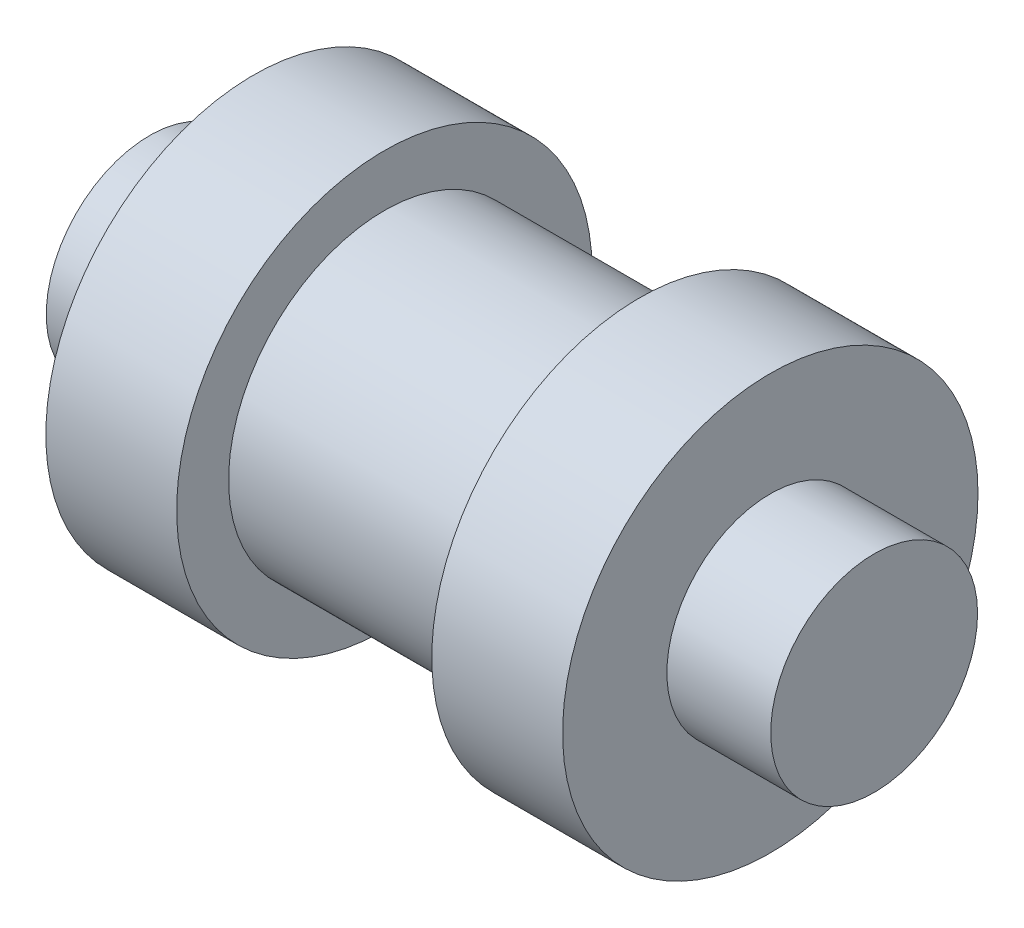
from build123d import *


with BuildPart() as part:
    # Sketch1 → Revolve1 (revolve)
    with BuildSketch(Plane.XY):
        Polygon((5.5375, 0), (-5.5375, 0), (-5.5375, 1.58115), (-3.95, 1.58115), (-3.95, 3.175), (-1.95, 3.175), (-1.95, 2.38125), (1.95, 2.38125), (1.95, 3.175), (3.95, 3.175), (3.95, 1.58115), (5.5375, 1.58115), align=None)
    revolve(axis=Axis((11.797676621, 0, 0), (-1, 0, 0)))


solid = part.part
